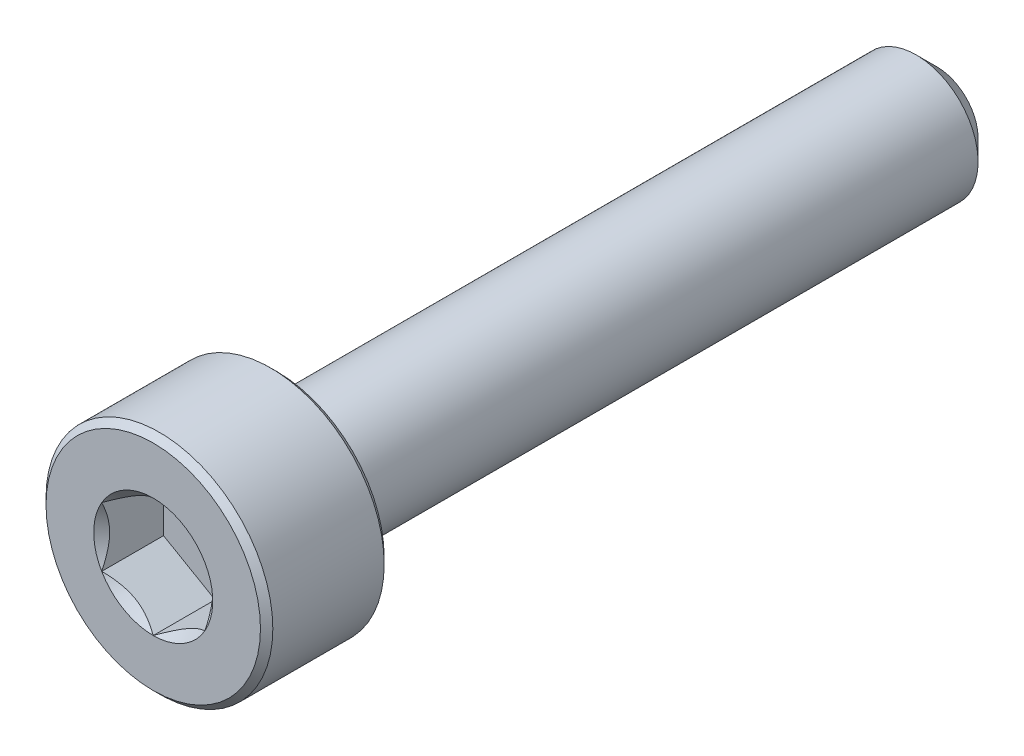
from build123d import *

# Parameters (mm, degrees)
CUT_EXTRUDE1_START = -1.5
CUT_EXTRUDE1_DEPTH = 1.5
SKETCH4_R          = 1.443375673
CUT_EXTRUDE2_DEPTH = 0.5
CUT_EXTRUDE2_TAPER = 45


with BuildPart() as part:
    # Sketch2 → Revolve1 (revolve)
    with BuildSketch(Plane(origin=(0, 0, 0), x_dir=(0, 0, -1), z_dir=(1, 0, 0))):
        Polygon((-9.35, 2.75), (-6.65, 2.75), (-6.5, 2.6), (-6.5, 1.5), (9, 1.5), (9.5, 1), (9.5, 0), (-9.5, 0), (-9.5, 2.6), align=None)
    revolve(axis=Axis((0, 0, -9.5), (0, 0, 1)))

    # Sketch3 → Cut-Extrude1 (cut)
    with BuildSketch(Plane.XY.offset(9.5).offset(CUT_EXTRUDE1_START)):
        Polygon((0, 1.443375673), (-1.25, 0.721687836), (-1.25, -0.721687836), (0, -1.443375673), (1.25, -0.721687836), (1.25, 0.721687836), align=None)
    extrude(amount=CUT_EXTRUDE1_DEPTH, mode=Mode.SUBTRACT)

    # Sketch4 → Cut-Extrude2 (cut)
    with BuildSketch(Plane.XY.offset(9.5)):
        Circle(SKETCH4_R)
    extrude(amount=-CUT_EXTRUDE2_DEPTH, taper=CUT_EXTRUDE2_TAPER, mode=Mode.SUBTRACT)


solid = part.part
